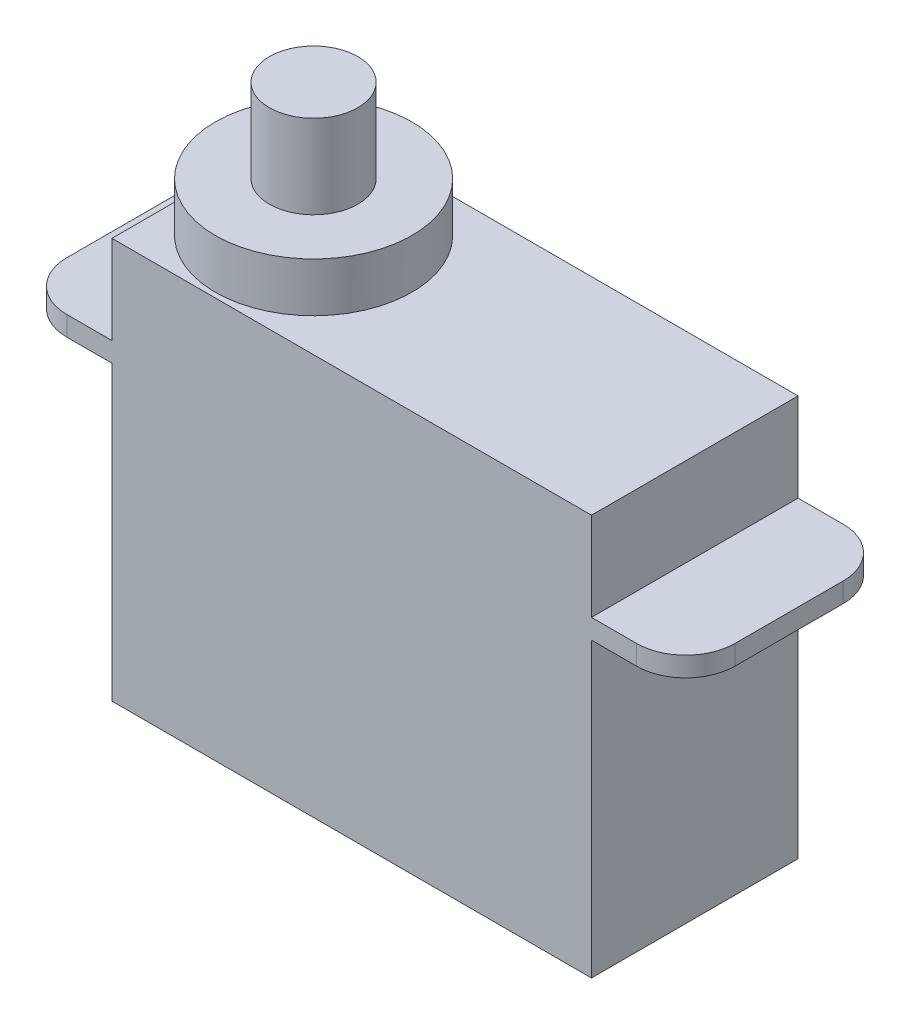
from build123d import *

# Parameters (mm, degrees)
SKETCH1_W           = 19.5
SKETCH1_H           = 8.4
BOSS_EXTRUDE1_DEPTH = 16.3
SKETCH2_R           = 4
BOSS_EXTRUDE2_DEPTH = 2
SKETCH3_W           = 8.4
SKETCH3_H           = 0.8
BOSS_EXTRUDE3_DEPTH = 3.835
FILLET1_R           = 2
FILLET2_R           = 2
SKETCH4_R           = 1.8
BOSS_EXTRUDE4_DEPTH = 3.4


with BuildPart() as part:
    # Sketch1 → Boss-Extrude1 (new body)
    with BuildSketch(Plane(origin=(0, 0, 0), x_dir=(1, 0, 0), z_dir=(0, 1, 0))):
        with Locations((9.75, 4.2)):
            Rectangle(SKETCH1_W, SKETCH1_H)
    extrude(amount=BOSS_EXTRUDE1_DEPTH)

    # Sketch2 → Boss-Extrude2 (add)
    with BuildSketch(Plane(origin=(0, 16.3, 0), x_dir=(1, 0, 0), z_dir=(0, 1, 0))):
        with Locations((4, 4.2)):
            Circle(SKETCH2_R)
    extrude(amount=BOSS_EXTRUDE2_DEPTH)

    # Sketch3 → Boss-Extrude3 (add)
    with BuildSketch(Plane(origin=(19.5, 0, 0), x_dir=(0, 0, -1), z_dir=(1, 0, 0))):
        with Locations((4.2, 12.3)):
            Rectangle(SKETCH3_W, SKETCH3_H)
    boss_extrude3 = extrude(amount=BOSS_EXTRUDE3_DEPTH)

    # Fillet1
    fillet1_edges = [part.edges().sort_by_distance(p)[0] for p in [
        (23.335, 12.3, 0),
        (23.335, 12.3, -8.4),
    ]]
    fillet(fillet1_edges, radius=FILLET1_R)

    # Mirror1: Boss-Extrude3 across plane
    add(boss_extrude3.mirror(Plane(origin=(9.75, 0, 0), x_dir=(0, 0, 1), z_dir=(1, 0, 0))))

    # Fillet2
    fillet2_edges = [part.edges().sort_by_distance(p)[0] for p in [
        (-3.835, 12.3, 0),
        (-3.835, 12.3, -8.4),
    ]]
    fillet(fillet2_edges, radius=FILLET2_R)

    # Sketch4 → Boss-Extrude4 (add)
    with BuildSketch(Plane(origin=(0, 18.3, 0), x_dir=(1, 0, 0), z_dir=(0, 1, 0))):
        with Locations((4, 4.2)):
            Circle(SKETCH4_R)
    extrude(amount=BOSS_EXTRUDE4_DEPTH)


solid = part.part
